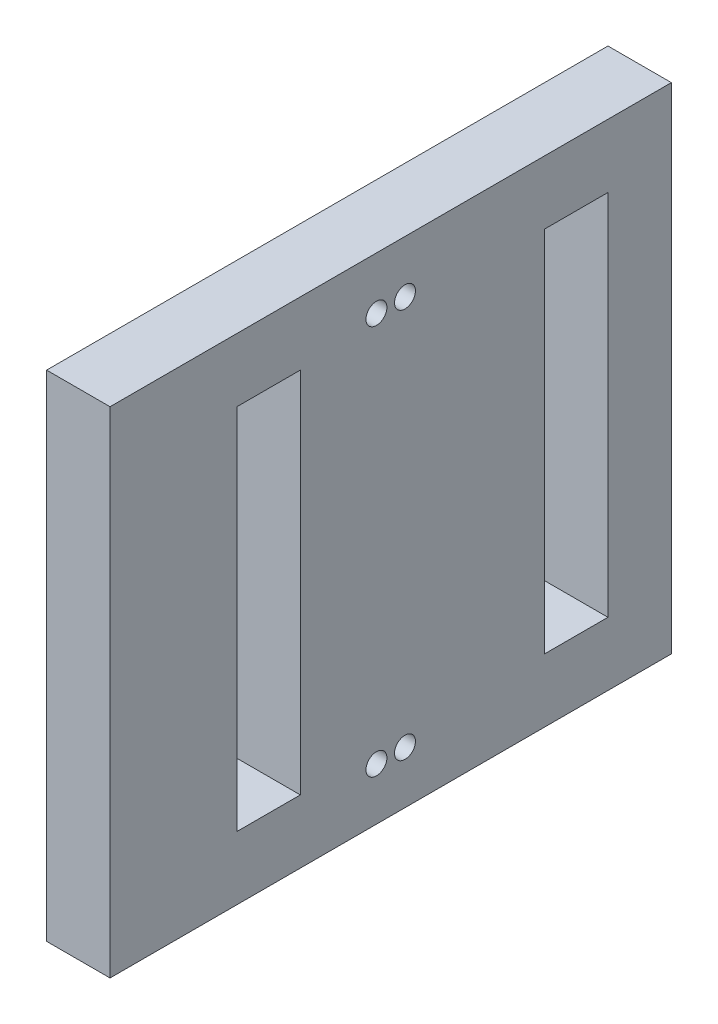
from build123d import *

# Parameters (mm, degrees)
SKETCH1_W           = 88.5
SKETCH1_H           = 78
SKETCH1_W_2         = 10
SKETCH1_H_2         = 58
BOSS_EXTRUDE1_DEPTH = 10
M4_TAPPED_HOLE1_D   = 3.3


with BuildPart() as part:
    # Sketch1 → Boss-Extrude1 (new body)
    with BuildSketch(Plane(origin=(0, 0, 0), x_dir=(0, 0, -1), z_dir=(1, 0, 0))):
        Rectangle(SKETCH1_W, SKETCH1_H)
        with Locations((-19.25, 0)):
            Rectangle(SKETCH1_W_2, SKETCH1_H_2, mode=Mode.SUBTRACT)
        with Locations((29.25, 0)):
            Rectangle(SKETCH1_W_2, SKETCH1_H_2, mode=Mode.SUBTRACT)
    extrude(amount=BOSS_EXTRUDE1_DEPTH)

    # M4 Tapped Hole1 (through all)
    with Locations(Plane(origin=(10, 0, 0), x_dir=(0, 0, -1), z_dir=(1, 0, 0))):
        with Locations((-2.25, -30.75), (-2.25, 30.75), (2.25, -30.75), (2.25, 30.75)):
            Hole(M4_TAPPED_HOLE1_D / 2)


solid = part.part
